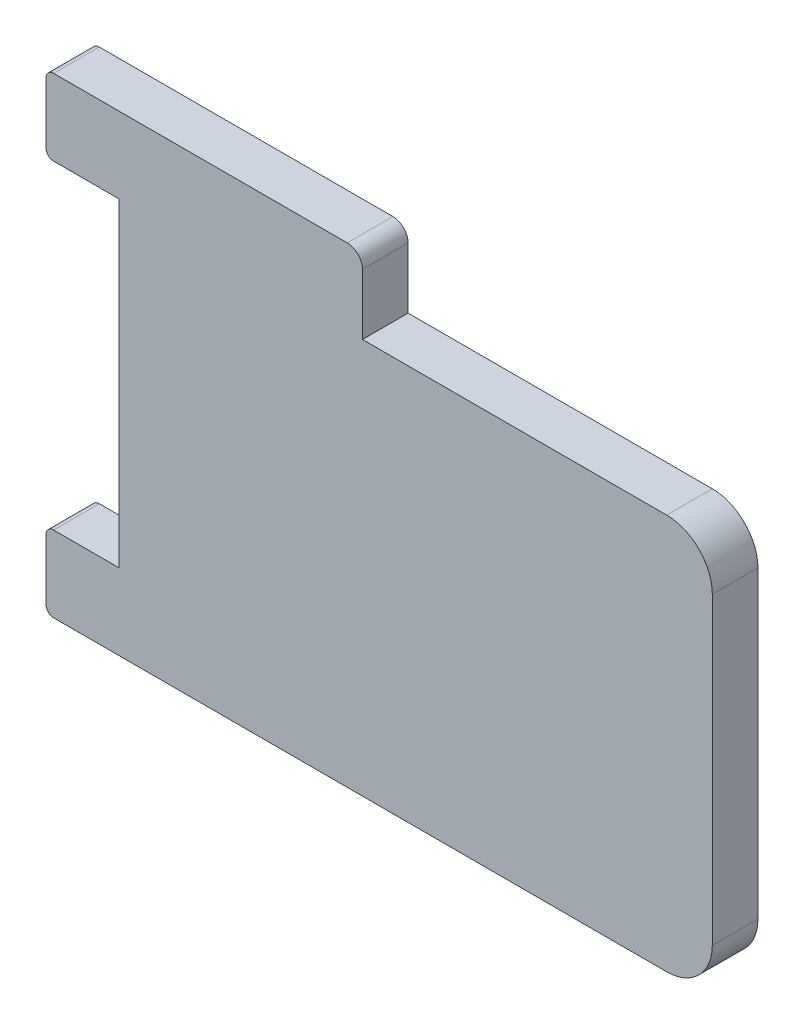
from build123d import *

# Parameters (mm, degrees)
SKETCH_1_W      = 4.8
SKETCH_1_H      = 5
EXTRUDE_1_DEPTH = 3
FILLET_1_R      = 0.5


with BuildPart() as part:
    # Эскиз1 → Бобышка-Вытянуть1 (new body)
    with BuildSketch(Plane.XY):
        with BuildLine():
            Line((-4.5, 15.5), (-19.5, 15.5))
            Line((-19.5, 15.5), (-19.5, 10.5))
            Line((-19.5, 10.5), (-19.5, -10.5))
            Line((-19.5, -10.5), (-19.5, -15.5))
            Line((-19.5, -15.5), (16.5, -15.5))
            ThreePointArc((16.5, -15.5), (18.621320344, -14.621320344), (19.5, -12.5))
            Line((19.5, -12.5), (19.5, 7.5))
            ThreePointArc((19.5, 7.5), (18.621320344, 9.621320344), (16.5, 10.5))
            Line((16.5, 10.5), (-3.5, 10.5))
            Line((-3.5, 10.5), (-3.5, 14.5))
            ThreePointArc((-3.5, 14.5), (-3.792893219, 15.207106781), (-4.5, 15.5))
        make_face()
        with Locations((-21.9, -13)):
            Rectangle(SKETCH_1_W, SKETCH_1_H)
        with Locations((-21.9, 13)):
            Rectangle(SKETCH_1_W, SKETCH_1_H)
    extrude(amount=EXTRUDE_1_DEPTH)

    # Скругление1
    fillet_1_edges = [part.edges().sort_by_distance(p)[0] for p in [
        (-24.3, -15.5, 1.5),
        (-24.3, -10.5, 1.5),
        (-24.3, 15.5, 1.5),
        (-24.3, 10.5, 1.5),
    ]]
    fillet(fillet_1_edges, radius=FILLET_1_R)


solid = part.part
